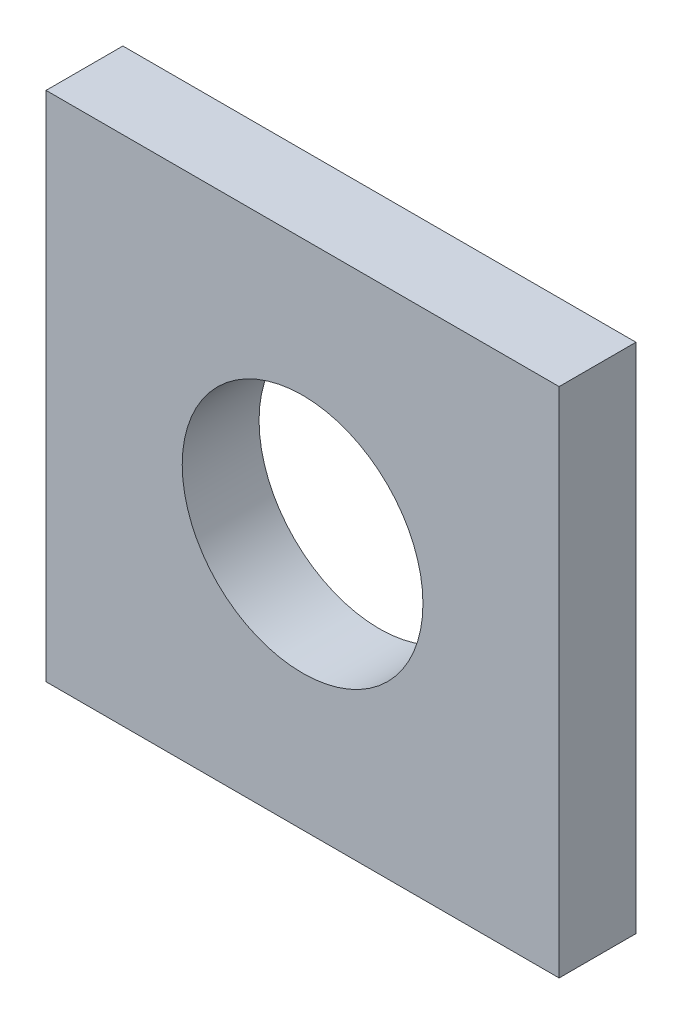
from build123d import *

# Parameters (mm, degrees)
ESQUISSE1_W        = 100.173670217
ESQUISSE1_H        = 100
ESQUISSE1_R        = 23.5
BOSS_EXTRU_1_DEPTH = 15


with BuildPart() as part:
    # Esquisse1 → Boss.-Extru.1 (new body)
    with BuildSketch(Plane.XY):
        with Locations((-26.246001082, -16.118829664)):
            Rectangle(ESQUISSE1_W, ESQUISSE1_H)
        with Locations((-26.246001082, -16.118829664)):
            Circle(ESQUISSE1_R, mode=Mode.SUBTRACT)
    extrude(amount=BOSS_EXTRU_1_DEPTH)


solid = part.part
